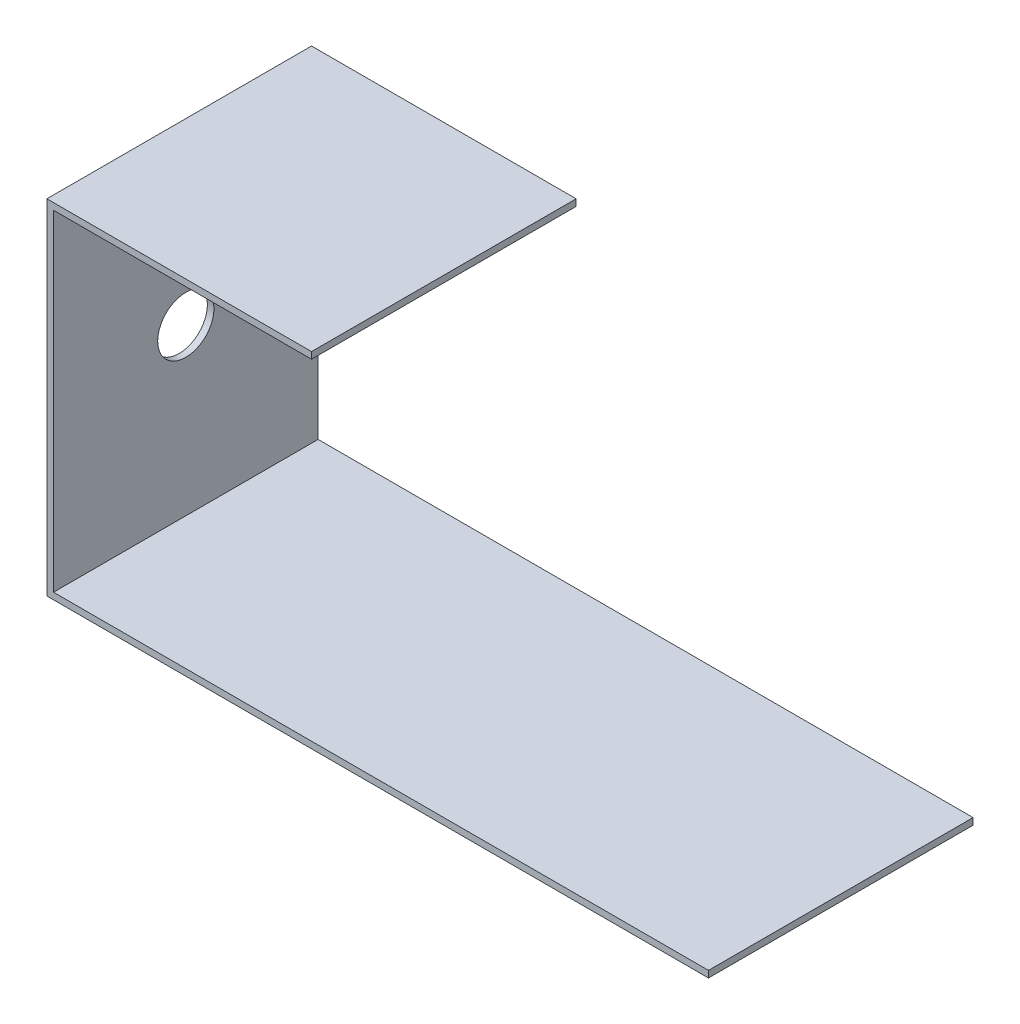
from build123d import *

# Parameters (mm, degrees)
BOSS_EXTRUDE1_DEPTH = 40
SKETCH2_R           = 4.25
CUT_EXTRUDE1_DEPTH  = 1


with BuildPart() as part:
    # Sketch1 → Boss-Extrude1 (new body)
    with BuildSketch(Plane.XY):
        Polygon((0, 0), (40, 0), (40, -1), (1, -1), (1, -51), (100, -51), (100, -52), (0, -52), align=None)
    extrude(amount=BOSS_EXTRUDE1_DEPTH)

    # Sketch2 → Cut-Extrude1 (cut)
    with BuildSketch(Plane.ZY):
        with Locations((20, -26)):
            Circle(SKETCH2_R)
    extrude(amount=-CUT_EXTRUDE1_DEPTH, mode=Mode.SUBTRACT)


solid = part.part
